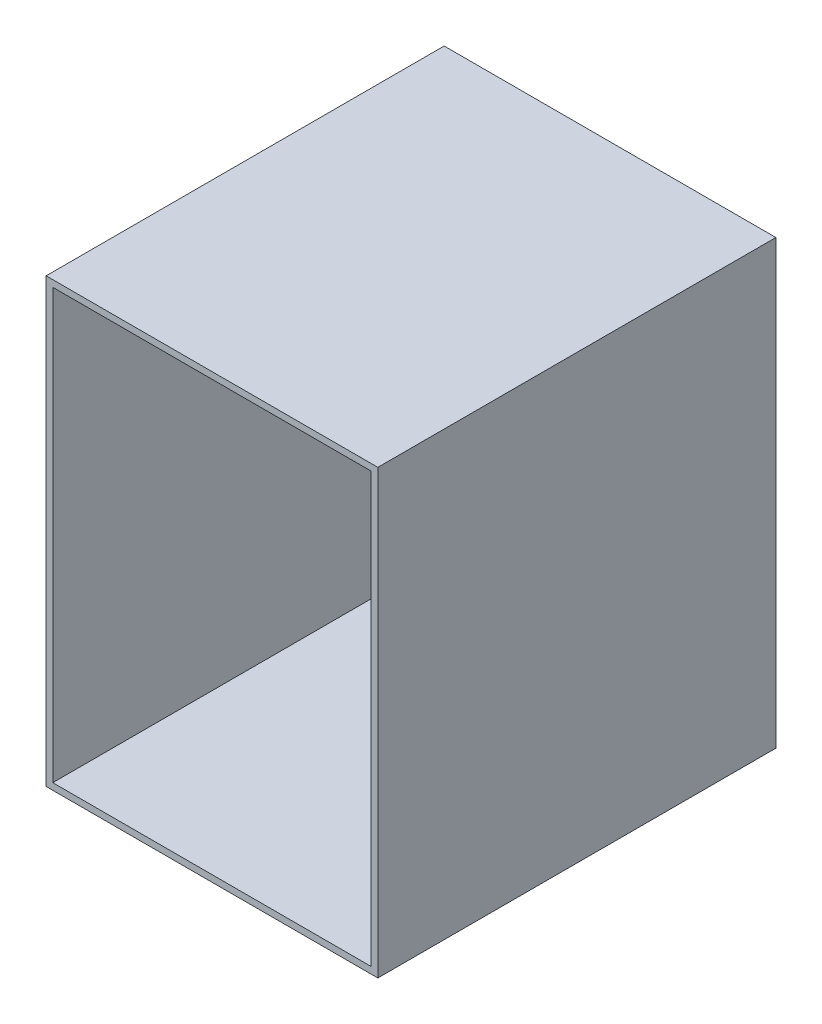
from build123d import *

# Parameters (mm, degrees)
SCHIZZO1_W                   = 150
SCHIZZO1_H                   = 200
ESTRUSIONE_ESTRUSIONE1_DEPTH = 180
SCHIZZO2_W                   = 144
SCHIZZO2_H                   = 194
TAGLIO_ESTRUSIONE1_DEPTH     = 175


with BuildPart() as part:
    # Schizzo1 → Estrusione-Estrusione1 (new body)
    with BuildSketch(Plane.XY):
        Rectangle(SCHIZZO1_W, SCHIZZO1_H)
    extrude(amount=ESTRUSIONE_ESTRUSIONE1_DEPTH)

    # Schizzo2 → Taglio-Estrusione1 (cut)
    with BuildSketch(Plane.XY.offset(180)):
        Rectangle(SCHIZZO2_W, SCHIZZO2_H)
    extrude(amount=-TAGLIO_ESTRUSIONE1_DEPTH, mode=Mode.SUBTRACT)


solid = part.part
